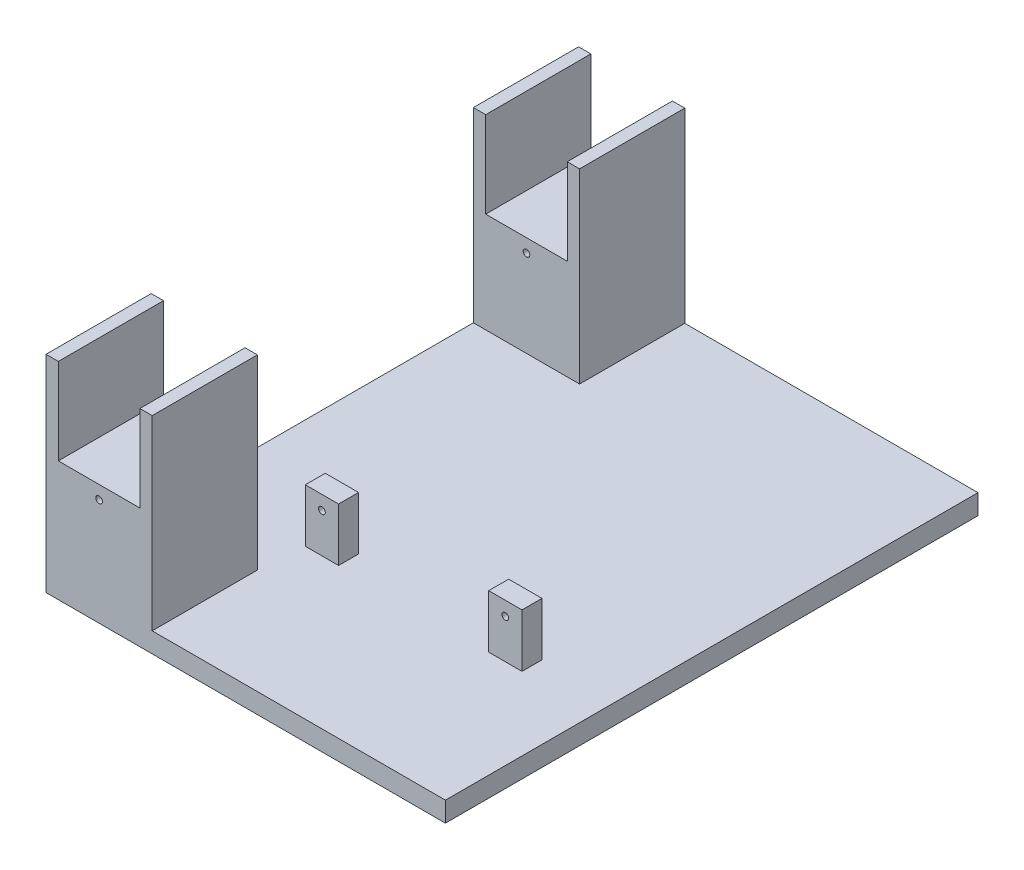
from build123d import *

# Parameters (mm, degrees)
SKETCH1_W           = 60
SKETCH1_H           = 80
BOSS_EXTRUDE1_DEPTH = 3
BOSS_EXTRUDE2_START = 40
SKETCH3_W           = 12.25
SKETCH3_H           = 15.056176196
SKETCH3_R           = 0.5
SKETCH3_W_2         = 1.85
SKETCH3_H_2         = 28
BOSS_EXTRUDE2_DEPTH = 15.8
BOSS_EXTRUDE3_START = -40
SKETCH3_3_W         = 12.25
SKETCH3_3_H         = 15.056176196
SKETCH3_3_R         = 0.5
SKETCH3_3_W_2       = 1.85
SKETCH3_3_H_2       = 28
BOSS_EXTRUDE3_DEPTH = 15.8
BOSS_EXTRUDE4_START = 14.5
SKETCH4_W           = 5
SKETCH4_H           = 8
SKETCH4_R           = 0.5
BOSS_EXTRUDE4_DEPTH = 3


with BuildPart() as part:
    # Sketch1 → Boss-Extrude1 (new body)
    with BuildSketch(Plane(origin=(0, 0, 0), x_dir=(1, 0, 0), z_dir=(0, 1, 0))):
        Rectangle(SKETCH1_W, SKETCH1_H)
    extrude(amount=BOSS_EXTRUDE1_DEPTH)

    # Sketch3 → Boss-Extrude2 (add)
    with BuildSketch(Plane.XY.offset(BOSS_EXTRUDE2_START)):
        Polygon((-15.9, 18.056176196), (-15.9, 3), (-14.05, 3), (-14.05, 31), (-15.9, 31), align=None)
        with Locations((-22.025, 10.528088098)):
            Rectangle(SKETCH3_W, SKETCH3_H)
        with Locations((-22.025, 16.056176196)):
            Circle(SKETCH3_R, mode=Mode.SUBTRACT)
        with Locations((-29.075, 17)):
            Rectangle(SKETCH3_W_2, SKETCH3_H_2)
    extrude(amount=-BOSS_EXTRUDE2_DEPTH)

    # Sketch3_3 → Boss-Extrude3 (add)
    with BuildSketch(Plane.XY.offset(BOSS_EXTRUDE3_START)):
        Polygon((-15.9, 18.056176196), (-15.9, 3), (-14.05, 3), (-14.05, 31), (-15.9, 31), align=None)
        with Locations((-22.025, 10.528088098)):
            Rectangle(SKETCH3_3_W, SKETCH3_3_H)
        with Locations((-22.025, 16.056176196)):
            Circle(SKETCH3_3_R, mode=Mode.SUBTRACT)
        with Locations((-29.075, 17)):
            Rectangle(SKETCH3_3_W_2, SKETCH3_3_H_2)
    extrude(amount=BOSS_EXTRUDE3_DEPTH)

    # Sketch4 → Boss-Extrude4 (add)
    with BuildSketch(Plane.XY.offset(BOSS_EXTRUDE4_START)):
        with Locations((16.5, 7)):
            Rectangle(SKETCH4_W, SKETCH4_H)
        with Locations((16.5, 8.9)):
            Circle(SKETCH4_R, mode=Mode.SUBTRACT)
        with Locations((-11.05, 7)):
            Rectangle(SKETCH4_W, SKETCH4_H)
        with Locations((-11.05, 8.9)):
            Circle(SKETCH4_R, mode=Mode.SUBTRACT)
    extrude(amount=BOSS_EXTRUDE4_DEPTH)


solid = part.part
